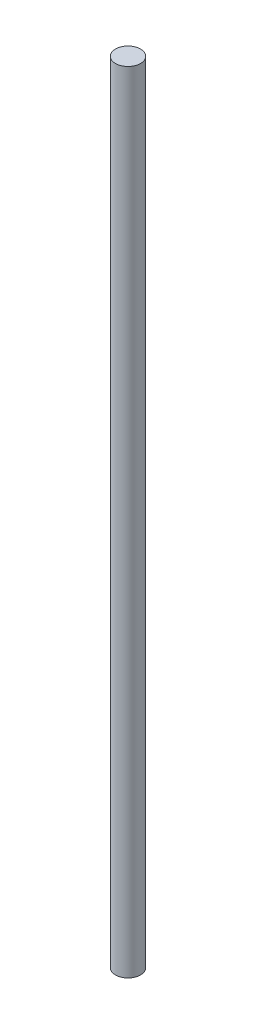
from build123d import *

# Parameters (mm, degrees)
SKETCH1_R                       = 3.175
BOSS_EXTRUDE1_DEPTH             = 200.025
F_32_0_116_DIAMETER_HOLE2_D     = 2.9464
F_32_0_116_DIAMETER_HOLE2_DEPTH = 3.6576
F_32_0_116_DIAMETER_HOLE2_TIP   = 0.885187864


with BuildPart() as part:
    # Sketch1 → Boss-Extrude1 (new body)
    with BuildSketch(Plane(origin=(0, 0, 0), x_dir=(1, 0, 0), z_dir=(0, 1, 0))):
        Circle(SKETCH1_R)
    extrude(amount=BOSS_EXTRUDE1_DEPTH)

    # #32 (0.116) Diameter Hole2
    with Locations(Plane(origin=(0, 0, 0), x_dir=(-1, 0, 0), z_dir=(0, -1, 0))):
        with Locations((0, 0)):
            Hole(F_32_0_116_DIAMETER_HOLE2_D / 2, depth=F_32_0_116_DIAMETER_HOLE2_DEPTH)
            with Locations((0, 0, -(F_32_0_116_DIAMETER_HOLE2_DEPTH + F_32_0_116_DIAMETER_HOLE2_TIP / 2))):  # 118° drill point
                Cone(0, F_32_0_116_DIAMETER_HOLE2_D / 2, F_32_0_116_DIAMETER_HOLE2_TIP, mode=Mode.SUBTRACT)


solid = part.part
